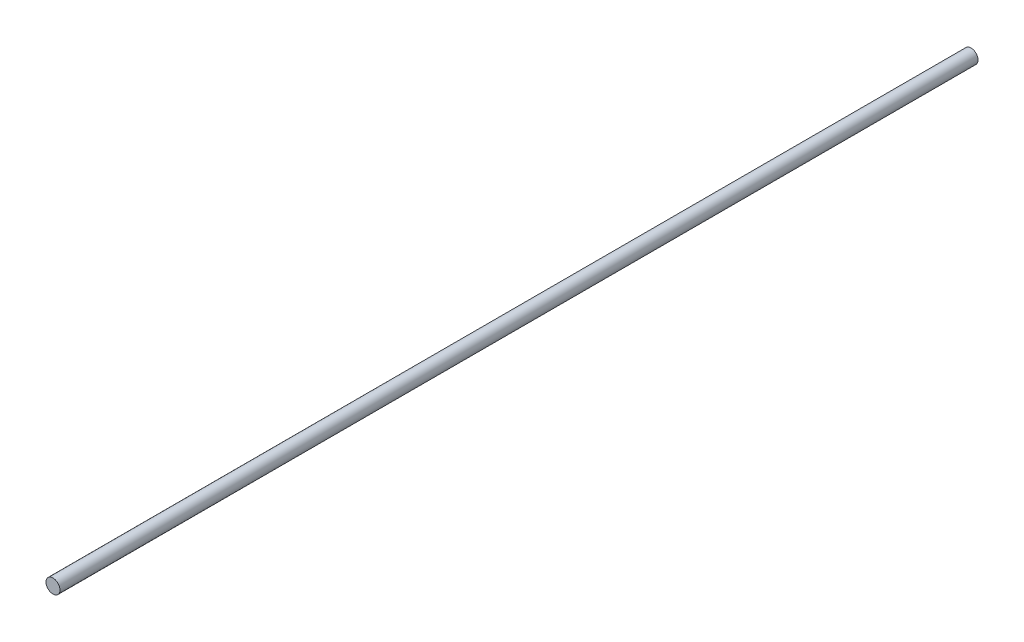
from build123d import *

# Parameters (mm, degrees)
SKETCH1_R           = 4.826
BOSS_EXTRUDE1_DEPTH = 635


with BuildPart() as part:
    # Sketch1 → Boss-Extrude1 (new body)
    with BuildSketch(Plane.XY):
        Circle(SKETCH1_R)
    extrude(amount=BOSS_EXTRUDE1_DEPTH)


solid = part.part
